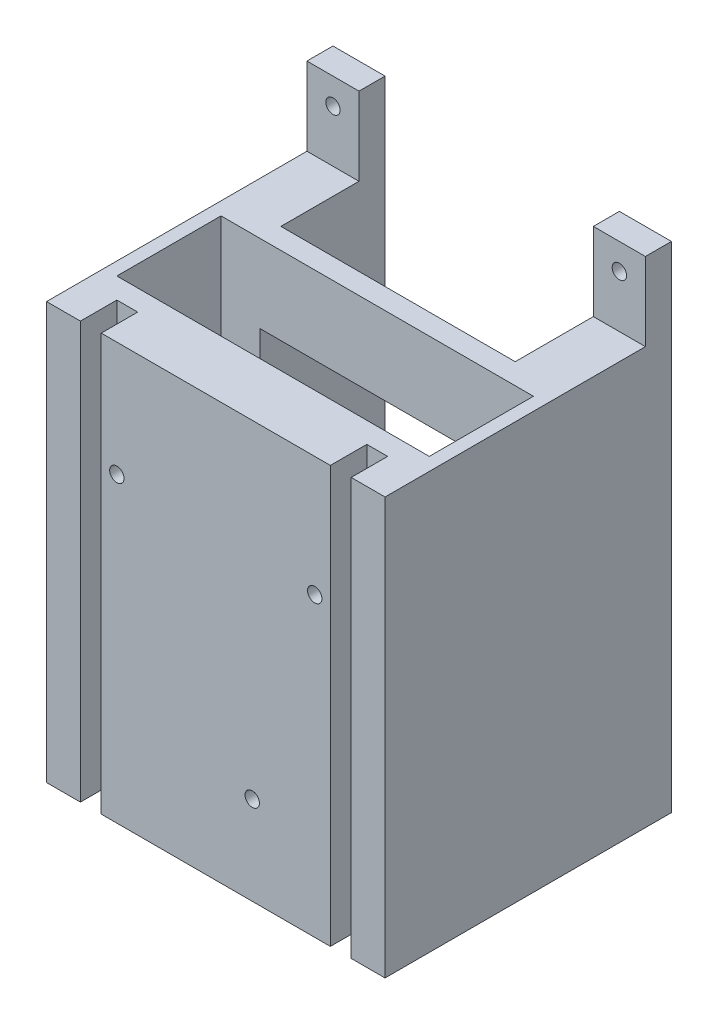
from build123d import *

# Parameters (mm, degrees)
SKETCH1_W                       = 82.55
SKETCH1_H                       = 120.65
BOSS_EXTRUDE1_DEPTH             = 69.85
SKETCH2_W                       = 76.2
SKETCH2_H                       = 25.4
CUT_EXTRUDE1_DEPTH              = 107.95
SKETCH3_W                       = 5.08
SKETCH3_H                       = 101.6
CUT_EXTRUDE2_DEPTH              = 8.89
SKETCH4_W                       = 63.5
SKETCH4_H                       = 19.05
CUT_EXTRUDE3_DEPTH              = 83.55
SKETCH5_W                       = 57.15
SKETCH5_H                       = 25.4
CUT_EXTRUDE4_DEPTH              = 121.65
F_40_0_138_DIAMETER_HOLE1_D     = 3.5052
F_40_0_138_DIAMETER_HOLE1_DEPTH = 13.97
BOSS_EXTRUDE2_DEPTH             = 6.35
SKETCH15_W                      = 57.15
SKETCH15_H                      = 88.9
CUT_EXTRUDE5_DEPTH              = 12.7
SKETCH16_W                      = 69.85
SKETCH16_H                      = 6.35
CUT_EXTRUDE6_DEPTH              = 83.55
SKETCH17_R                      = 1.7526
CUT_EXTRUDE7_DEPTH              = 6.35


with BuildPart() as part:
    # Sketch1 → Boss-Extrude1 (new body)
    with BuildSketch(Plane.XY):
        with Locations((0, 79.375)):
            Rectangle(SKETCH1_W, SKETCH1_H)
    extrude(amount=BOSS_EXTRUDE1_DEPTH)

    # Sketch2 → Cut-Extrude1 (cut)
    with BuildSketch(Plane(origin=(0, 139.7, 0), x_dir=(1, 0, 0), z_dir=(0, 1, 0))):
        with Locations((0, -43.18)):
            Rectangle(SKETCH2_W, SKETCH2_H)
    extrude(amount=-CUT_EXTRUDE1_DEPTH, mode=Mode.SUBTRACT)

    # Sketch3 → Cut-Extrude2 (cut)
    with BuildSketch(Plane.XY.offset(69.85)):
        with Locations((30.48, 69.85)):
            Rectangle(SKETCH3_W, SKETCH3_H)
    cut_extrude2 = extrude(amount=-CUT_EXTRUDE2_DEPTH, mode=Mode.SUBTRACT)

    # Mirror1: Cut-Extrude2 across plane
    add(cut_extrude2.mirror(Plane(origin=(0, 0, 0), x_dir=(0, 0, 1), z_dir=(1, 0, 0))), mode=Mode.SUBTRACT)

    # Sketch4 → Cut-Extrude3 (cut, through all)
    with BuildSketch(Plane.ZY.offset(41.275)):
        with Locations((38.1, 130.175)):
            Rectangle(SKETCH4_W, SKETCH4_H)
    extrude(amount=-CUT_EXTRUDE3_DEPTH, mode=Mode.SUBTRACT)

    # Sketch5 → Cut-Extrude4 (cut, through all)
    with BuildSketch(Plane(origin=(0, 139.7, 0), x_dir=(1, 0, 0), z_dir=(0, 1, 0))):
        with Locations((0, -12.7)):
            Rectangle(SKETCH5_W, SKETCH5_H)
    extrude(amount=-CUT_EXTRUDE4_DEPTH, mode=Mode.SUBTRACT)

    # #40 (0.138) Diameter Hole1
    with Locations(Plane.XY.offset(69.85)):
        with Locations((-24.130002345, 92.720002179), (24.129997606, 91.450000321), (8.889995651, 40.650000908)):
            Hole(F_40_0_138_DIAMETER_HOLE1_D / 2, depth=F_40_0_138_DIAMETER_HOLE1_DEPTH)

    # Sketch14 → Boss-Extrude2 (add)
    with BuildSketch(Plane.XZ.offset(-19.05)):
        Polygon((-41.275, 69.85), (-33.02, 69.85), (-33.02, 60.96), (-27.94, 60.96), (-27.94, 69.85), (27.94, 69.85), (27.94, 60.96), (33.02, 60.96), (33.02, 69.85), (41.275, 69.85), (41.275, 0), (28.575, 0), (28.575, 25.4), (-28.575, 25.4), (-28.575, 0), (-41.275, 0), align=None)
    extrude(amount=BOSS_EXTRUDE2_DEPTH)

    # Sketch15 → Cut-Extrude5 (cut)
    with BuildSketch(Plane(origin=(0, 0, 25.4), x_dir=(-1, 0, 0), z_dir=(0, 0, -1))):
        with Locations((0, 57.15)):
            Rectangle(SKETCH15_W, SKETCH15_H)
    extrude(amount=-CUT_EXTRUDE5_DEPTH, mode=Mode.SUBTRACT)

    # Sketch16 → Cut-Extrude6 (cut, through all)
    with BuildSketch(Plane(origin=(41.275, 0, 0), x_dir=(0, 0, -1), z_dir=(1, 0, 0))):
        with Locations((-34.925, 15.875)):
            Rectangle(SKETCH16_W, SKETCH16_H)
    extrude(amount=-CUT_EXTRUDE6_DEPTH, mode=Mode.SUBTRACT)

    # Sketch17 → Cut-Extrude7 (cut)
    with BuildSketch(Plane.XY.offset(6.35)):
        with Locations((-34.925, 133.35)):
            Circle(SKETCH17_R)
    cut_extrude7 = extrude(amount=-CUT_EXTRUDE7_DEPTH, mode=Mode.SUBTRACT)

    # Mirror2: Cut-Extrude7 across plane
    add(cut_extrude7.mirror(Plane(origin=(0, 0, 0), x_dir=(0, 0, 1), z_dir=(1, 0, 0))), mode=Mode.SUBTRACT)


solid = part.part
